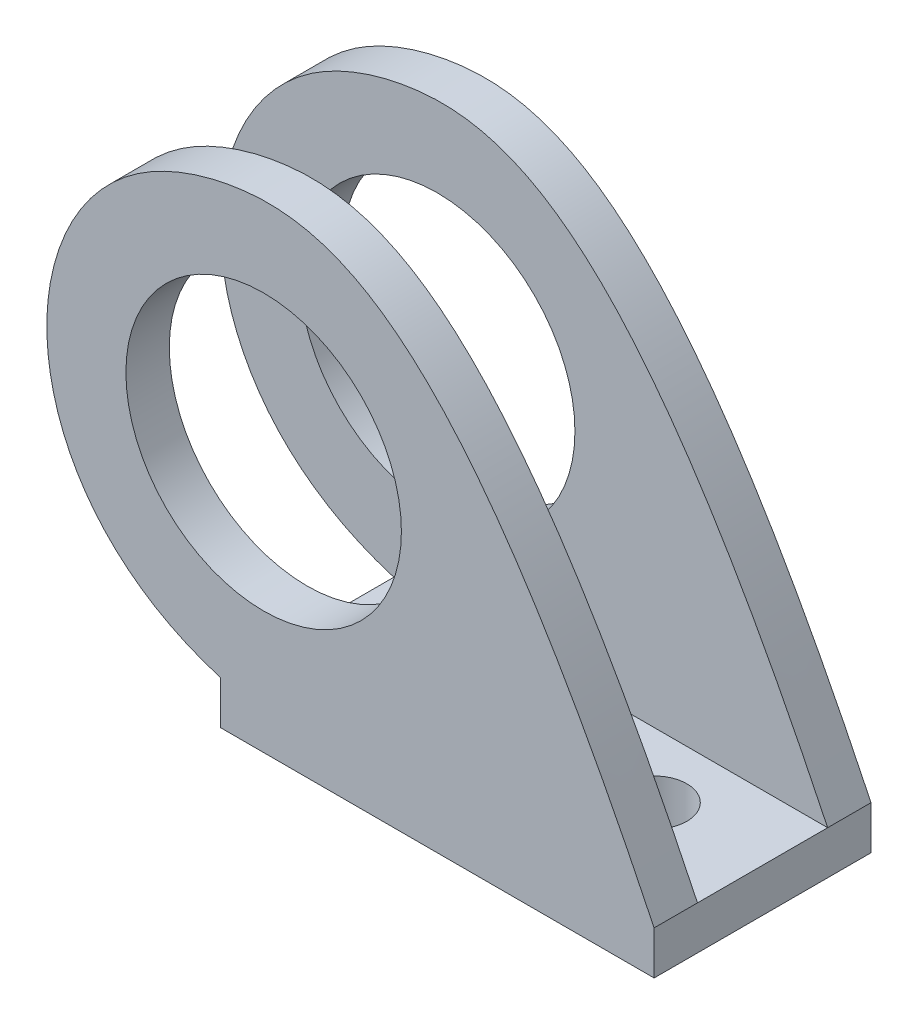
from build123d import *

# Parameters (mm, degrees)
SKETCH1_W           = 20
SKETCH1_H           = 10
SKETCH1_R           = 1.5
BOSS_EXTRUDE1_DEPTH = 2
SKETCH2_R           = 6.35
BOSS_EXTRUDE2_DEPTH = 2
BOSS_EXTRUDE3_START = -8
SKETCH2_3_R         = 6.35
BOSS_EXTRUDE3_DEPTH = 2


with BuildPart() as part:
    # Sketch1 → Boss-Extrude1 (new body)
    with BuildSketch(Plane(origin=(0, 0, 0), x_dir=(1, 0, 0), z_dir=(0, 1, 0))):
        Rectangle(SKETCH1_W, SKETCH1_H)
        with Locations((-5, 0.01)):
            Circle(SKETCH1_R, mode=Mode.SUBTRACT)
        with Locations((5, 0.01)):
            Circle(SKETCH1_R, mode=Mode.SUBTRACT)
    extrude(amount=BOSS_EXTRUDE1_DEPTH)

    # Sketch2 → Boss-Extrude2 (add)
    with BuildSketch(Plane.XY.offset(5)):
        with BuildLine():
            Line((-10, 2), (-10, 0))
            Line((-10, 0), (10, 0))
            Line((10, 0), (10, 2))
            add(Edge.make_bspline(
                [(-10, 2), (-19.934312567, 5.008938653), (-20.001123005, 18.401993577), (-5.496887853, 23.599149902), (1.470480463, 19.813788664), (10, 2)],
                knots=[0, 0, 0, 0, 0.526796962, 0.626796962, 1, 1, 1, 1], degree=3))
        make_face()
        with Locations((-8, 12)):
            Circle(SKETCH2_R, mode=Mode.SUBTRACT)
    extrude(amount=-BOSS_EXTRUDE2_DEPTH)

    # Sketch2_3 → Boss-Extrude3 (add)
    with BuildSketch(Plane.XY.offset(5).offset(BOSS_EXTRUDE3_START)):
        with BuildLine():
            Line((-10, 2), (-10, 0))
            Line((-10, 0), (10, 0))
            Line((10, 0), (10, 2))
            add(Edge.make_bspline(
                [(-10, 2), (-19.934312567, 5.008938653), (-20.001123005, 18.401993577), (-5.496887853, 23.599149902), (1.470480463, 19.813788664), (10, 2)],
                knots=[0, 0, 0, 0, 0.526796962, 0.626796962, 1, 1, 1, 1], degree=3))
        make_face()
        with Locations((-8, 12)):
            Circle(SKETCH2_3_R, mode=Mode.SUBTRACT)
    extrude(amount=-BOSS_EXTRUDE3_DEPTH)


solid = part.part
